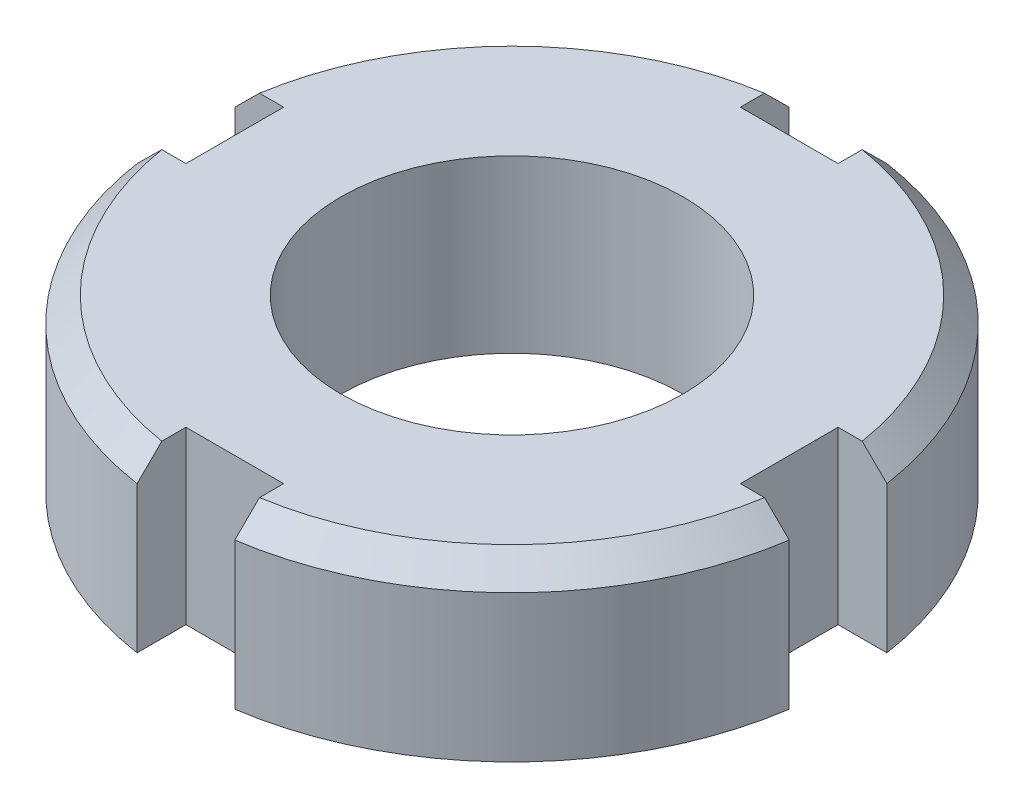
from build123d import *

# Parameters (mm, degrees)
SKETCH1_R               = 13.5
BOSS_EXTRUDE1_DEPTH     = 3.5
CUT_EXTRUDE1_DEPTH      = 4.5
CUT_EXTRUDE1_DEPTH_BACK = 4.5
CHAMFER1_SIZE           = 1
M16_TAPPED_HOLE1_D      = 14
M16_TAPPED_HOLE1_DEPTH  = 7


with BuildPart() as part:
    # Sketch1 → Boss-Extrude1 (new body, symmetric)
    with BuildSketch(Plane(origin=(0, 0, 0), x_dir=(1, 0, 0), z_dir=(0, 1, 0))):
        Circle(SKETCH1_R)
    extrude(amount=BOSS_EXTRUDE1_DEPTH, both=True)

    # Sketch2 → Cut-Extrude1 (cut, two sides)
    with BuildSketch(Plane(origin=(0, 0, 0), x_dir=(1, 0, 0), z_dir=(0, 1, 0))) as cut_extrude1_sk:
        with BuildLine():
            Line((-2, 13.351029923), (-2, 11.351029923))
            Line((-2, 11.351029923), (2, 11.351029923))
            Line((2, 11.351029923), (2, 13.351029923))
            ThreePointArc((2, 13.351029923), (0, 13.5), (-2, 13.351029923))
        make_face()
        with BuildLine():
            Line((13.351029923, 2), (11.351029923, 2))
            Line((11.351029923, 2), (11.351029923, -2))
            Line((11.351029923, -2), (13.351029923, -2))
            ThreePointArc((13.351029923, -2), (13.5, 0), (13.351029923, 2))
        make_face()
        with BuildLine():
            Line((2, -13.351029923), (2, -11.351029923))
            Line((2, -11.351029923), (-2, -11.351029923))
            Line((-2, -11.351029923), (-2, -13.351029923))
            ThreePointArc((-2, -13.351029923), (0, -13.5), (2, -13.351029923))
        make_face()
        with BuildLine():
            Line((-13.351029923, -2), (-11.351029923, -2))
            Line((-11.351029923, -2), (-11.351029923, 2))
            Line((-11.351029923, 2), (-13.351029923, 2))
            ThreePointArc((-13.351029923, 2), (-13.5, 0), (-13.351029923, -2))
        make_face()
    extrude(amount=CUT_EXTRUDE1_DEPTH, mode=Mode.SUBTRACT)
    extrude(cut_extrude1_sk.sketch, amount=-CUT_EXTRUDE1_DEPTH_BACK, mode=Mode.SUBTRACT)

    # Chamfer1
    chamfer1_edges = [part.edges().sort_by_distance(p)[0] for p in [
        (9.545941546, 3.5, -9.545941546),
        (-9.545941546, 3.5, -9.545941546),
        (-9.545941546, 3.5, 9.545941546),
        (9.545941546, 3.5, 9.545941546),
    ]]
    chamfer(chamfer1_edges, length=CHAMFER1_SIZE)

    # M16 Tapped Hole1
    with Locations(Plane(origin=(0, 3.5, 0), x_dir=(1, 0, 0), z_dir=(0, 1, 0))):
        with Locations((0, 0)):
            Hole(M16_TAPPED_HOLE1_D / 2, depth=M16_TAPPED_HOLE1_DEPTH)


solid = part.part
